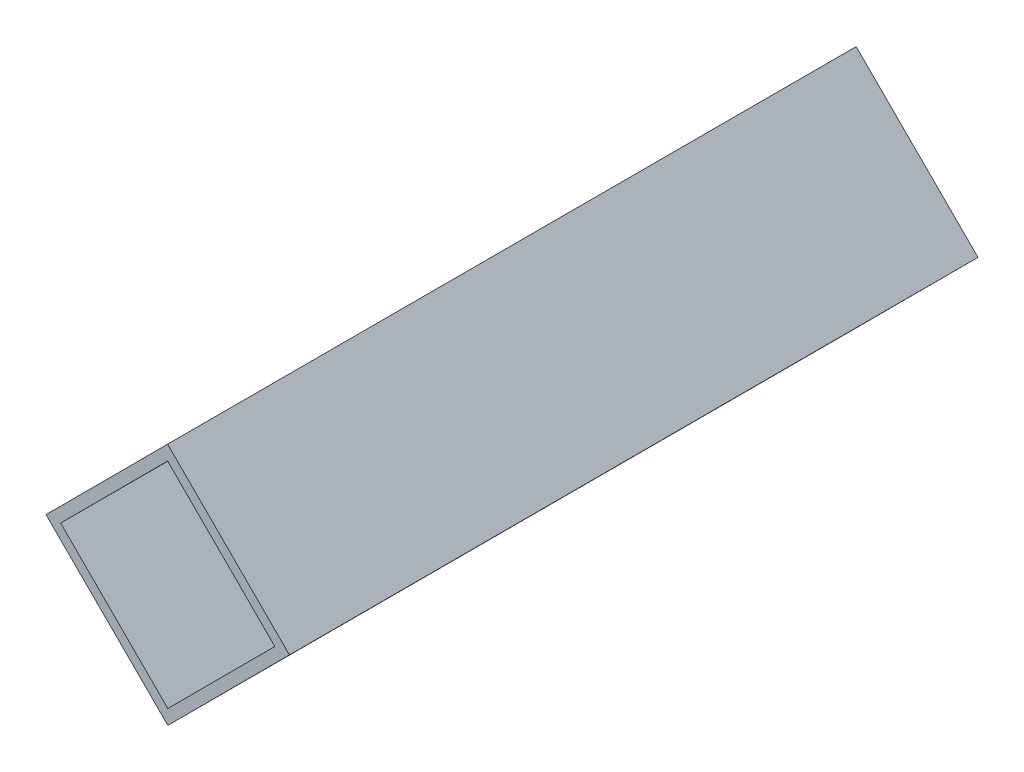
from build123d import *

# Parameters (mm, degrees)
EXTRUDE_1_DEPTH = 100


with BuildPart() as part:
    # 草圖1 → 填料-伸長1 (new body)
    with BuildSketch(Plane.XY):
        Polygon((0, 0), (17.69379362, -17.661530719), (0.032262901, -35.355324339), (-17.661530719, -17.69379362), align=None)
        Polygon((0.001935774, -2.12131946), (-15.540211259, -17.691857846), (0.030327127, -33.234004879), (15.57247416, -17.663466493), align=None, mode=Mode.SUBTRACT)
    extrude(amount=EXTRUDE_1_DEPTH)


solid = part.part
